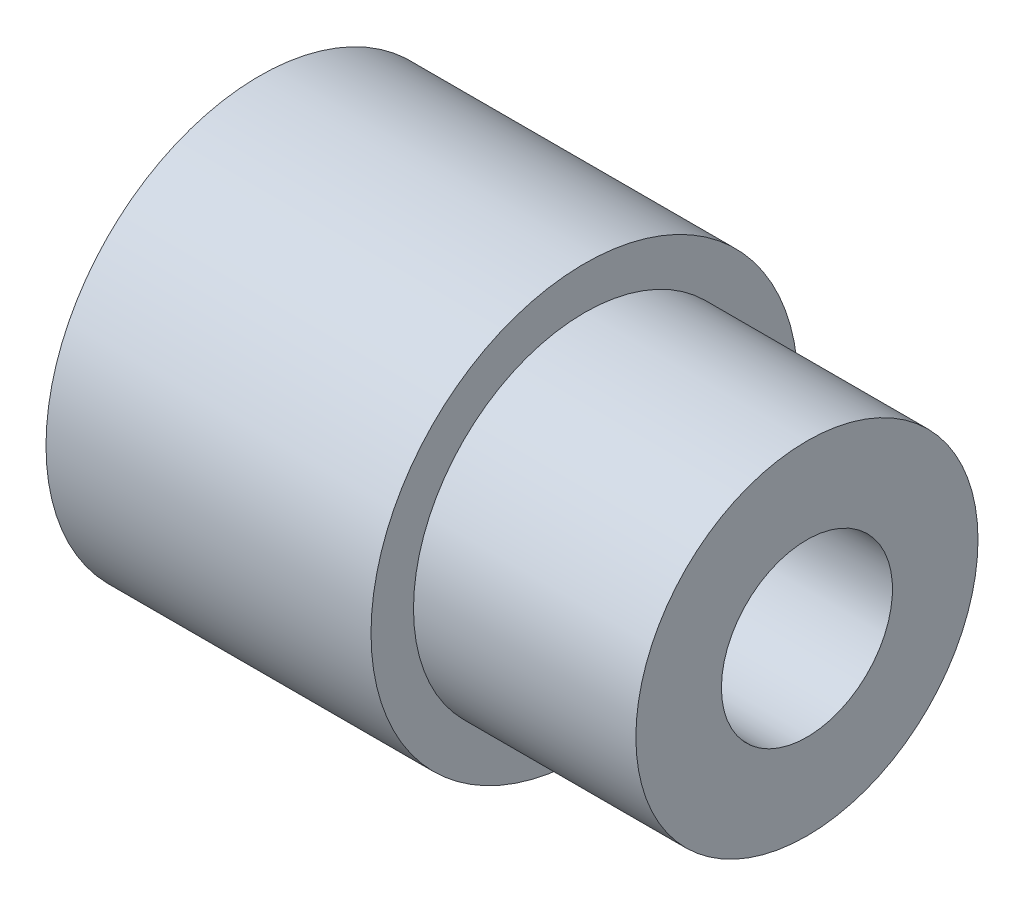
from build123d import *


with BuildPart() as part:
    # Sketch1 → Revolve1 (revolve)
    with BuildSketch(Plane.XY):
        Polygon((-32, 9.4836701), (-32, 12.4836701), (-13, 12.4836701), (-13, 10), (0, 10), (0, 5), (-16, 5), (-16, 7.4836701), (-26, 7.4836701), (-26, 9.4836701), align=None)
    revolve(axis=Axis((-17.229134297, 0, 0), (1, 0, 0)))


solid = part.part
